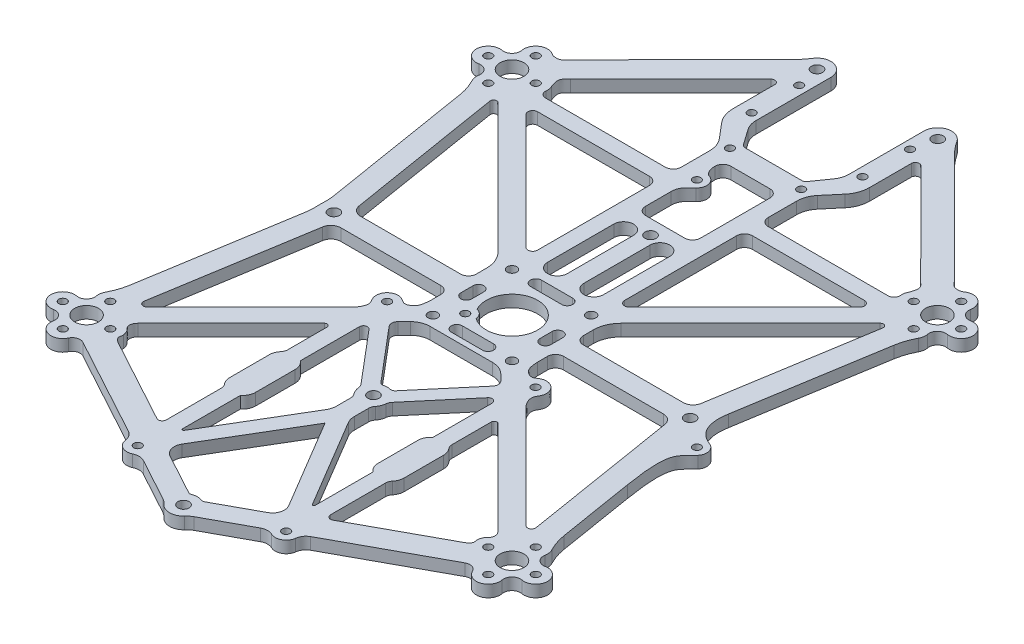
from build123d import *

# Parameters (mm, degrees)
SKETCH_1_R             = 3
SKETCH_1_R_2           = 1.4
SKETCH_1_R_3           = 1.2
SKETCH_1_R_4           = 6.5
SKETCH_1_R_5           = 1
EXTRUDE_1_DEPTH        = 3
SKETCH_3_R             = 2.5
SKETCH_3_R_2           = 1
EXTRUDE_7644_DEPTH     = 3
SKETCH_4_R             = 1
CUT_EXTRUDE_7905_DEPTH = 3


with BuildPart() as part:
    # 草图1 → 凸台-拉伸1 (new body)
    with BuildSketch(Plane(origin=(0, 0, 0), x_dir=(1, 0, 0), z_dir=(0, 1, 0))):
        with BuildLine():
            Line((-54.817916589, 41.679245914), (-48.646861458, 3.735023629))
            ThreePointArc((-48.646861458, 3.735023629), (-48.467327534, 1.997597312), (-48.49098251, 0.251079899))
            ThreePointArc((-48.49098251, 0.251079899), (-48.5, 0), (-48.49098251, -0.251079899))
            ThreePointArc((-48.49098251, -0.251079899), (-48.467327534, -1.997597312), (-48.646861458, -3.735023629))
            Line((-48.646861458, -3.735023629), (-54.817916589, -41.679245914))
            ThreePointArc((-54.817916589, -41.679245914), (-55.411166239, -44.068510137), (-56.387231876, -46.328559815))
            ThreePointArc((-56.387231876, -46.328559815), (-56.705703037, -47.287666611), (-56.687629603, -48.298103683))
            ThreePointArc((-56.687629603, -48.298103683), (-57.275533906, -50.204466094), (-59.181896317, -50.792370397))
            ThreePointArc((-59.181896317, -50.792370397), (-62.74, -53.74), (-59.181896317, -56.687629603))
            ThreePointArc((-59.181896317, -56.687629603), (-57.275533906, -57.275533906), (-56.687629603, -59.181896317))
            ThreePointArc((-56.687629603, -59.181896317), (-54.668601571, -62.592665267), (-51.02866658, -61.024005875))
            ThreePointArc((-51.02866658, -61.024005875), (-49.846342294, -59.983233235), (-48.27779537, -60.127312923))
            Line((-48.27779537, -60.127312923), (-23.022972919, -73.868492835))
            ThreePointArc((-23.022972919, -73.868492835), (-21.97669751, -74.815722708), (-21.479329577, -76.136541319))
            ThreePointArc((-21.479329577, -76.136541319), (-20.06432318, -78.215585763), (-17.550122212, -78.274427872))
            ThreePointArc((-17.550122212, -78.274427872), (-16.170972145, -77.974625009), (-14.80735752, -78.338619264))
            Line((-14.80735752, -78.338619264), (-3.95680415, -84.242418678))
            ThreePointArc((-3.95680415, -84.242418678), (-3.238991405, -84.717315042), (-2.613257566, -85.308279385))
            ThreePointArc((-2.613257566, -85.308279385), (0, -86.48), (2.613257566, -85.308279385))
            ThreePointArc((2.613257566, -85.308279385), (3.238991405, -84.717315042), (3.95680415, -84.242418678))
            Line((3.95680415, -84.242418678), (14.80735752, -78.338619264))
            ThreePointArc((14.80735752, -78.338619264), (16.170972145, -77.974625009), (17.550122212, -78.274427872))
            ThreePointArc((17.550122212, -78.274427872), (20.06432318, -78.215585763), (21.479329577, -76.136541319))
            ThreePointArc((21.479329577, -76.136541319), (21.97669751, -74.815722708), (23.022972919, -73.868492835))
            Line((23.022972919, -73.868492835), (48.27779537, -60.127312923))
            ThreePointArc((48.27779537, -60.127312923), (49.846342294, -59.983233235), (51.02866658, -61.024005875))
            ThreePointArc((51.02866658, -61.024005875), (54.668601571, -62.592665267), (56.687629603, -59.181896317))
            ThreePointArc((56.687629603, -59.181896317), (57.275533906, -57.275533906), (59.181896317, -56.687629603))
            ThreePointArc((59.181896317, -56.687629603), (62.74, -53.74), (59.181896317, -50.792370397))
            ThreePointArc((59.181896317, -50.792370397), (57.275533906, -50.204466094), (56.687629603, -48.298103683))
            ThreePointArc((56.687629603, -48.298103683), (56.705703037, -47.287666611), (56.387231876, -46.328559815))
            ThreePointArc((56.387231876, -46.328559815), (55.411166239, -44.068510137), (54.817916589, -41.679245914))
            Line((54.817916589, -41.679245914), (48.646861458, -3.735023629))
            ThreePointArc((48.646861458, -3.735023629), (48.467327534, -1.997597312), (48.49098251, -0.251079899))
            ThreePointArc((48.49098251, -0.251079899), (48.5, 0), (48.49098251, 0.251079899))
            ThreePointArc((48.49098251, 0.251079899), (48.467327534, 1.997597312), (48.646861458, 3.735023629))
            Line((48.646861458, 3.735023629), (54.817916589, 41.679245914))
            ThreePointArc((54.817916589, 41.679245914), (55.411166239, 44.068510137), (56.387231876, 46.328559815))
            ThreePointArc((56.387231876, 46.328559815), (56.705703037, 47.287666611), (56.687629603, 48.298103683))
            ThreePointArc((56.687629603, 48.298103683), (57.275533906, 50.204466094), (59.181896317, 50.792370397))
            ThreePointArc((59.181896317, 50.792370397), (62.74, 53.74), (59.181896317, 56.687629603))
            ThreePointArc((59.181896317, 56.687629603), (57.275533906, 57.275533906), (56.687629603, 59.181896317))
            ThreePointArc((56.687629603, 59.181896317), (55.338265706, 62.278808132), (51.962363808, 62.156611175))
            add(Edge.make_bspline(
                [(51.962363808, 62.156611175), (51.696992634, 61.961406663), (50.926121561, 61.800184127), (49.494642895, 61.880063213), (48.851457079, 62.883933878), (48.496350597, 63.239686175)],
                knots=[0, 0, 0, 0, 0.236574091, 0.582738494, 1, 1, 1, 1], degree=3))
            Line((48.496350597, 63.239686175), (20.779693132, 91.006750656))
            ThreePointArc((20.779693132, 91.006750656), (19.397862757, 92.54208186), (18.181759519, 94.211749492))
            ThreePointArc((18.181759519, 94.211749492), (14.252793481, 95.654933555), (11.75, 92.3))
            Line((11.75, 92.3), (11.75, 73.360558254))
            ThreePointArc((11.75, 73.360558254), (11.518584754, 71.857029257), (10.845760221, 70.492676073))
            Line((10.845760221, 70.492676073), (8.033549939, 66.476423564))
            ThreePointArc((8.033549939, 66.476423564), (7.676146508, 66.162989167), (7.214397895, 66.05))
            Line((7.214397895, 66.05), (-7.214397895, 66.05))
            ThreePointArc((-7.214397895, 66.05), (-7.676146508, 66.162989167), (-8.033549939, 66.476423564))
            Line((-8.033549939, 66.476423564), (-10.845760221, 70.492676073))
            ThreePointArc((-10.845760221, 70.492676073), (-11.518584754, 71.857029257), (-11.75, 73.360558254))
            Line((-11.75, 73.360558254), (-11.75, 92.3))
            ThreePointArc((-11.75, 92.3), (-14.252793481, 95.654933555), (-18.181759519, 94.211749492))
            ThreePointArc((-18.181759519, 94.211749492), (-19.397862757, 92.54208186), (-20.779693132, 91.006750656))
            Line((-20.779693132, 91.006750656), (-48.496350597, 63.239686175))
            add(Edge.make_bspline(
                [(-51.962363808, 62.156611175), (-51.696992634, 61.961406663), (-50.926121561, 61.800184127), (-49.494642895, 61.880063213), (-48.851457079, 62.883933878), (-48.496350597, 63.239686175)],
                knots=[0, 0, 0, 0, 0.236574091, 0.582738494, 1, 1, 1, 1], degree=3))
            ThreePointArc((-51.962363808, 62.156611175), (-55.338265706, 62.278808132), (-56.687629603, 59.181896317))
            ThreePointArc((-56.687629603, 59.181896317), (-57.275533906, 57.275533906), (-59.181896317, 56.687629603))
            ThreePointArc((-59.181896317, 56.687629603), (-62.74, 53.74), (-59.181896317, 50.792370397))
            ThreePointArc((-59.181896317, 50.792370397), (-57.275533906, 50.204466094), (-56.687629603, 48.298103683))
            ThreePointArc((-56.687629603, 48.298103683), (-56.705703037, 47.287666611), (-56.387231876, 46.328559815))
            ThreePointArc((-56.387231876, 46.328559815), (-55.411166239, 44.068510137), (-54.817916589, 41.679245914))
        make_face()
        with Locations((53.74, 53.74)):
            Circle(SKETCH_1_R, mode=Mode.SUBTRACT)
        with Locations((53.74, -53.74)):
            Circle(SKETCH_1_R, mode=Mode.SUBTRACT)
        with Locations((-53.74, -53.74)):
            Circle(SKETCH_1_R, mode=Mode.SUBTRACT)
        with Locations((-53.74, 53.74)):
            Circle(SKETCH_1_R, mode=Mode.SUBTRACT)
        with Locations((15.25, 92.3)):
            Circle(SKETCH_1_R_2, mode=Mode.SUBTRACT)
        with Locations((45, 0)):
            Circle(SKETCH_1_R_2, mode=Mode.SUBTRACT)
        with Locations((0, -82.98)):
            Circle(SKETCH_1_R_2, mode=Mode.SUBTRACT)
        with Locations((-45, 0)):
            Circle(SKETCH_1_R_2, mode=Mode.SUBTRACT)
        with Locations((-15.25, 92.3)):
            Circle(SKETCH_1_R_2, mode=Mode.SUBTRACT)
        with Locations((-10, 10)):
            Circle(SKETCH_1_R_3, mode=Mode.SUBTRACT)
        with Locations((-10, -10)):
            Circle(SKETCH_1_R_3, mode=Mode.SUBTRACT)
        with Locations((10, -10)):
            Circle(SKETCH_1_R_3, mode=Mode.SUBTRACT)
        with Locations((10, 10)):
            Circle(SKETCH_1_R_3, mode=Mode.SUBTRACT)
        Circle(SKETCH_1_R_4, mode=Mode.SUBTRACT)
        with Locations((53.74, 59.74)):
            Circle(SKETCH_1_R_5, mode=Mode.SUBTRACT)
        with Locations((59.74, 53.74)):
            Circle(SKETCH_1_R_5, mode=Mode.SUBTRACT)
        with Locations((53.74, 47.74)):
            Circle(SKETCH_1_R_5, mode=Mode.SUBTRACT)
        with Locations((47.74, 53.74)):
            Circle(SKETCH_1_R_5, mode=Mode.SUBTRACT)
        with Locations((-59.74, 53.74)):
            Circle(SKETCH_1_R_5, mode=Mode.SUBTRACT)
        with Locations((-53.74, 47.74)):
            Circle(SKETCH_1_R_5, mode=Mode.SUBTRACT)
        with Locations((-47.74, 53.74)):
            Circle(SKETCH_1_R_5, mode=Mode.SUBTRACT)
        with Locations((-53.74, 59.74)):
            Circle(SKETCH_1_R_5, mode=Mode.SUBTRACT)
        with Locations((59.74, -53.74)):
            Circle(SKETCH_1_R_5, mode=Mode.SUBTRACT)
        with Locations((47.74, -53.74)):
            Circle(SKETCH_1_R_5, mode=Mode.SUBTRACT)
        with Locations((53.74, -47.74)):
            Circle(SKETCH_1_R_5, mode=Mode.SUBTRACT)
        with Locations((53.74, -59.74)):
            Circle(SKETCH_1_R_5, mode=Mode.SUBTRACT)
        with Locations((-59.74, -53.74)):
            Circle(SKETCH_1_R_5, mode=Mode.SUBTRACT)
        with Locations((-53.74, -47.74)):
            Circle(SKETCH_1_R_5, mode=Mode.SUBTRACT)
        with Locations((-53.74, -59.74)):
            Circle(SKETCH_1_R_5, mode=Mode.SUBTRACT)
        with Locations((-47.74, -53.74)):
            Circle(SKETCH_1_R_5, mode=Mode.SUBTRACT)
        with Locations((0, 35)):
            Circle(SKETCH_1_R_2, mode=Mode.SUBTRACT)
        with Locations((0, -35)):
            Circle(SKETCH_1_R_2, mode=Mode.SUBTRACT)
        with Locations((-14, 86.55)):
            Circle(SKETCH_1_R_5, mode=Mode.SUBTRACT)
        with Locations((-14, 74.55)):
            Circle(SKETCH_1_R_5, mode=Mode.SUBTRACT)
        with Locations((-9, 64.05)):
            Circle(SKETCH_1_R_5, mode=Mode.SUBTRACT)
        with Locations((-18.75, -12.8)):
            Circle(SKETCH_1_R_5, mode=Mode.SUBTRACT)
        with Locations((18.75, -12.8)):
            Circle(SKETCH_1_R_5, mode=Mode.SUBTRACT)
        with Locations((-18.75, -75.8)):
            Circle(SKETCH_1_R_5, mode=Mode.SUBTRACT)
        with Locations((18.75, -75.8)):
            Circle(SKETCH_1_R_5, mode=Mode.SUBTRACT)
        with Locations((9, 64.05)):
            Circle(SKETCH_1_R_5, mode=Mode.SUBTRACT)
        with Locations((14, 74.55)):
            Circle(SKETCH_1_R_5, mode=Mode.SUBTRACT)
        with Locations((14, 86.55)):
            Circle(SKETCH_1_R_5, mode=Mode.SUBTRACT)
        with BuildLine():
            Line((-44.249857219, 59.000901681), (-18.957748896, 84.339007603))
            ThreePointArc((-18.957748896, 84.339007603), (-17.86773628, 84.556596792), (-17.25, 83.63254352))
            Line((-17.25, 83.63254352), (-17.25, 73.07312754))
            ThreePointArc((-17.25, 73.07312754), (-16.822346942, 70.663925251), (-15.591641236, 68.549095169))
            Line((-15.591641236, 68.549095169), (-12.421450369, 64.805969374))
            ThreePointArc((-12.421450369, 64.805969374), (-11.366559764, 62.993257875), (-11, 60.928227341))
            Line((-11, 60.928227341), (-11, 53.74))
            ThreePointArc((-11, 53.74), (-11.585786438, 52.325786438), (-13, 51.74))
            Line((-13, 51.74), (-43.267864045, 51.74))
            ThreePointArc((-43.267864045, 51.74), (-44.385898034, 52.24), (-44.75857603, 53.406666667))
            ThreePointArc((-44.75857603, 53.406666667), (-44.784640519, 54.255606765), (-45.047586477, 55.063219339))
            add(Edge.make_bspline(
                [(-44.249857219, 59.000901681), (-44.657956515, 58.592060194), (-45.738298836, 57.797656509), (-45.460089937, 56.24706939), (-45.211821974, 55.397396645), (-45.047586477, 55.063219339)],
                knots=[0, 0, 0, 0, 0.434879643, 0.72183386, 1, 1, 1, 1], degree=3))
        make_face(mode=Mode.SUBTRACT)
        with BuildLine():
            Line((-49.630496457, 44.045545745), (-43.215059938, 4.598685496))
            ThreePointArc((-43.215059938, 4.598685496), (-42.367158841, 3.095625265), (-40.747480827, 2.5))
            Line((-40.747480827, 2.5), (-15.5, 2.5))
            ThreePointArc((-15.5, 2.5), (-14.085786438, 3.085786438), (-13.5, 4.5))
            Line((-13.5, 4.5), (-13.5, 7.064971157))
            ThreePointArc((-13.5, 7.064971157), (-14.032843272, 9.743755184), (-15.550252532, 12.014718626))
            Line((-15.550252532, 12.014718626), (-48.275185717, 44.739651811))
            ThreePointArc((-48.275185717, 44.739651811), (-49.205539589, 44.886017595), (-49.630496457, 44.045545745))
        make_face(mode=Mode.SUBTRACT)
        with BuildLine():
            Line((-42.155937957, 45.691471863), (-13.048528137, 16.584062043))
            ThreePointArc((-13.048528137, 16.584062043), (-11.740779881, 16.323934742), (-11, 17.432590181))
            Line((-11, 17.432590181), (-11, 45.74))
            ThreePointArc((-11, 45.74), (-11.585786438, 47.154213562), (-13, 47.74))
            Line((-13, 47.74), (-41.307409819, 47.74))
            ThreePointArc((-41.307409819, 47.74), (-42.416065258, 46.999220119), (-42.155937957, 45.691471863))
        make_face(mode=Mode.SUBTRACT)
        with BuildLine():
            Line((-40.747480827, -2.5), (-15.5, -2.5))
            ThreePointArc((-15.5, -2.5), (-14.085786438, -3.085786438), (-13.5, -4.5))
            Line((-13.5, -4.5), (-13.5, -7.064971157))
            add(Edge.make_bspline(
                [(-13.5, -7.064971157), (-13.5, -7.532275591), (-13.629768419, -8.480482385), (-13.985423095, -10.173330441), (-15.944235554, -11.538035465), (-17.345060978, -10.327437308), (-18.921839327, -9.849782143), (-20.914131435, -10.605251441), (-21.628856588, -12.450245795), (-21.337349804, -14.041338042), (-20.598792194, -14.921596282), (-20.539303092, -16.58070944), (-21.327386728, -17.791852822), (-21.820098193, -18.284564287)],
                knots=[0, 0, 0, 0, 0.081236858, 0.151161291, 0.290886124, 0.364496537, 0.432695755, 0.558641359, 0.672327414, 0.727732225, 0.821151545, 0.848565537, 1, 1, 1, 1], degree=3))
            Line((-21.820098193, -18.284564287), (-47.83684746, -44.301313554))
            ThreePointArc((-47.83684746, -44.301313554), (-48.9997898, -44.484270784), (-49.530985886, -43.433680972))
            Line((-49.530985886, -43.433680972), (-43.215059938, -4.598685496))
            ThreePointArc((-43.215059938, -4.598685496), (-42.367158841, -3.095625265), (-40.747480827, -2.5))
        make_face(mode=Mode.SUBTRACT)
        with BuildLine():
            Line((-43.59403656, -55.845110493), (-22.227935702, -67.47043221))
            ThreePointArc((-22.227935702, -67.47043221), (-21.239086946, -67.45166978), (-20.75, -66.592037387))
            Line((-20.75, -66.592037387), (-20.75, -52.700367627))
            ThreePointArc((-20.75, -52.700367627), (-20.872818729, -52.010302068), (-21.226190476, -51.404989483))
            ThreePointArc((-21.226190476, -51.404989483), (-21.800419565, -50.421356534), (-22, -49.3))
            Line((-22, -49.3), (-22, -39.3))
            ThreePointArc((-22, -39.3), (-21.800419565, -38.178643466), (-21.226190476, -37.195010517))
            ThreePointArc((-21.226190476, -37.195010517), (-20.872818729, -36.589697932), (-20.75, -35.899632373))
            Line((-20.75, -35.899632373), (-20.75, -25.9754834))
            ThreePointArc((-20.75, -25.9754834), (-21.182121597, -25.328767727), (-21.944974747, -25.480508653))
            Line((-21.944974747, -25.480508653), (-45.455950582, -48.991484488))
            add(Edge.make_bspline(
                [(-45.455950582, -48.991484488), (-45.968825857, -49.504359763), (-46.231848976, -50.320991769), (-46.097739166, -51.156730053), (-45.659351377, -51.578773194)],
                knots=[0, 0, 0, 0, 0.559210432, 1, 1, 1, 1], degree=3))
            ThreePointArc((-45.659351377, -51.578773194), (-45.040245498, -52.431823549), (-44.754405413, -53.446359128))
            add(Edge.make_bspline(
                [(-44.754405413, -53.446359128), (-44.717532318, -53.821266454), (-45.054582612, -54.453906843), (-44.43789803, -55.362150007), (-43.821770894, -55.721199962), (-43.59403656, -55.845110493)],
                knots=[0, 0, 0, 0, 0.347316286, 0.678667105, 1, 1, 1, 1], degree=3))
        make_face(mode=Mode.SUBTRACT)
        with BuildLine():
            Line((-2.102452168, 32.785933541), (-2.102452168, 16.071116731))
            ThreePointArc((-2.102452168, 16.071116731), (-4.590561624, 13.583007274), (-7.078671081, 16.071116731))
            Line((-7.078671081, 16.071116731), (-7.078671081, 32.785933541))
            ThreePointArc((-7.078671081, 32.785933541), (-4.590561624, 35.274042997), (-2.102452168, 32.785933541))
        make_face(mode=Mode.SUBTRACT)
        with BuildLine():
            Line((-14.986026632, -21.131025078), (-3.950386049, -34.197223528))
            ThreePointArc((-3.950386049, -34.197223528), (-3.632393684, -34.717973125), (-3.486211772, -35.310366688))
            ThreePointArc((-3.486211772, -35.310366688), (-3.24142846, -36.320280856), (-2.710911113, -37.213811405))
            ThreePointArc((-2.710911113, -37.213811405), (-2.376099766, -37.807349706), (-2.260003178, -38.478846494))
            Line((-2.260003178, -38.478846494), (-2.260003178, -42.108681952))
            ThreePointArc((-2.260003178, -42.108681952), (-2.403276188, -43.169651756), (-2.82283164, -44.154617391))
            Line((-2.82283164, -44.154617391), (-16.192212135, -66.615176622))
            ThreePointArc((-16.192212135, -66.615176622), (-16.529572735, -66.750985989), (-16.75, -66.461731464))
            Line((-16.75, -66.461731464), (-16.75, -51.861737691))
            ThreePointArc((-16.75, -51.861737691), (-15.829169639, -50.725219281), (-15.5, -49.3))
            Line((-15.5, -49.3), (-15.5, -39.3))
            ThreePointArc((-15.5, -39.3), (-15.829169639, -37.874780719), (-16.75, -36.738262309))
            Line((-16.75, -36.738262309), (-16.75, -21.776272854))
            ThreePointArc((-16.75, -21.776272854), (-16.093530663, -20.837131393), (-14.986026632, -21.131025078))
        make_face(mode=Mode.SUBTRACT)
        with BuildLine():
            Line((7.900505063, -12.8), (-7.900505063, -12.8))
            ThreePointArc((-7.900505063, -12.8), (-9.813922225, -13.180602337), (-11.436038969, -14.264466094))
            Line((-11.436038969, -14.264466094), (-12.980899852, -15.809326977))
            ThreePointArc((-12.980899852, -15.809326977), (-13.448116309, -16.873477139), (-13.07188639, -17.97309427))
            Line((-13.07188639, -17.97309427), (-1.837103576, -31.275077122))
            ThreePointArc((-1.837103576, -31.275077122), (-1.382307289, -31.580833831), (-0.834656829, -31.600978379))
            ThreePointArc((-0.834656829, -31.600978379), (0, -31.5), (0.834656829, -31.600978379))
            ThreePointArc((0.834656829, -31.600978379), (1.382307289, -31.580833831), (1.837103576, -31.275077122))
            Line((1.837103576, -31.275077122), (13.07188639, -17.97309427))
            ThreePointArc((13.07188639, -17.97309427), (13.448116309, -16.873477139), (12.980899852, -15.809326977))
            Line((12.980899852, -15.809326977), (11.436038969, -14.264466094))
            ThreePointArc((11.436038969, -14.264466094), (9.813922225, -13.180602337), (7.900505063, -12.8))
        make_face(mode=Mode.SUBTRACT)
        with BuildLine():
            Line((0, -47.232643858), (-13.476555361, -69.873256865))
            ThreePointArc((-13.476555361, -69.873256865), (-13.791749788, -72.20151456), (-12.332483813, -74.042892913))
            Line((-12.332483813, -74.042892913), (-1.964243599, -79.684265147))
            ThreePointArc((-1.964243599, -79.684265147), (-1.630493999, -79.780071762), (-1.287588984, -79.725447095))
            ThreePointArc((-1.287588984, -79.725447095), (0, -79.48), (1.287588984, -79.725447095))
            ThreePointArc((1.287588984, -79.725447095), (1.630493999, -79.780071762), (1.964243599, -79.684265147))
            Line((1.964243599, -79.684265147), (12.332483813, -74.042892913))
            ThreePointArc((12.332483813, -74.042892913), (13.791749788, -72.20151456), (13.476555361, -69.873256865))
            Line((13.476555361, -69.873256865), (0, -47.232643858))
        make_face(mode=Mode.SUBTRACT)
        with BuildLine():
            Line((2.102452168, 32.785933541), (2.102452168, 16.071116731))
            ThreePointArc((2.102452168, 16.071116731), (4.590561624, 13.583007274), (7.078671081, 16.071116731))
            Line((7.078671081, 16.071116731), (7.078671081, 32.785933541))
            ThreePointArc((7.078671081, 32.785933541), (4.590561624, 35.274042997), (2.102452168, 32.785933541))
        make_face(mode=Mode.SUBTRACT)
        with BuildLine():
            Line((16.75, -51.861737691), (16.75, -66.461731464))
            ThreePointArc((16.75, -66.461731464), (16.529572735, -66.750985989), (16.192212135, -66.615176622))
            Line((16.192212135, -66.615176622), (2.82283164, -44.154617391))
            ThreePointArc((2.82283164, -44.154617391), (2.403276188, -43.169651756), (2.260003178, -42.108681952))
            Line((2.260003178, -42.108681952), (2.260003178, -38.478846494))
            ThreePointArc((2.260003178, -38.478846494), (2.376099766, -37.807349706), (2.710911113, -37.213811405))
            ThreePointArc((2.710911113, -37.213811405), (3.24142846, -36.320280856), (3.486211772, -35.310366688))
            ThreePointArc((3.486211772, -35.310366688), (3.632393684, -34.717973125), (3.950386049, -34.197223528))
            Line((3.950386049, -34.197223528), (14.986026632, -21.131025078))
            ThreePointArc((14.986026632, -21.131025078), (16.093530663, -20.837131393), (16.75, -21.776272854))
            Line((16.75, -21.776272854), (16.75, -36.738262309))
            ThreePointArc((16.75, -36.738262309), (15.829169639, -37.874780719), (15.5, -39.3))
            Line((15.5, -39.3), (15.5, -49.3))
            ThreePointArc((15.5, -49.3), (15.829169639, -50.725219281), (16.75, -51.861737691))
        make_face(mode=Mode.SUBTRACT)
        with BuildLine():
            Line((22, -39.3), (22, -49.3))
            ThreePointArc((22, -49.3), (21.800419565, -50.421356534), (21.226190476, -51.404989483))
            ThreePointArc((21.226190476, -51.404989483), (20.872818729, -52.010302068), (20.75, -52.700367627))
            Line((20.75, -52.700367627), (20.75, -66.592037387))
            ThreePointArc((20.75, -66.592037387), (21.239086946, -67.45166978), (22.227935702, -67.47043221))
            Line((22.227935702, -67.47043221), (43.59403656, -55.845110493))
            add(Edge.make_bspline(
                [(44.754405413, -53.446359128), (44.717532318, -53.821266454), (45.054582612, -54.453906843), (44.43789803, -55.362150007), (43.821770894, -55.721199962), (43.59403656, -55.845110493)],
                knots=[0, 0, 0, 0, 0.347316286, 0.678667105, 1, 1, 1, 1], degree=3))
            ThreePointArc((44.754405413, -53.446359128), (45.040245498, -52.431823549), (45.659351377, -51.578773194))
            add(Edge.make_bspline(
                [(45.455950582, -48.991484488), (45.968825857, -49.504359763), (46.231848976, -50.320991769), (46.097739166, -51.156730053), (45.659351377, -51.578773194)],
                knots=[0, 0, 0, 0, 0.559210432, 1, 1, 1, 1], degree=3))
            Line((45.455950582, -48.991484488), (21.944974747, -25.480508653))
            ThreePointArc((21.944974747, -25.480508653), (21.182121597, -25.328767727), (20.75, -25.9754834))
            Line((20.75, -25.9754834), (20.75, -35.899632373))
            ThreePointArc((20.75, -35.899632373), (20.872818729, -36.589697932), (21.226190476, -37.195010517))
            ThreePointArc((21.226190476, -37.195010517), (21.800419565, -38.178643466), (22, -39.3))
        make_face(mode=Mode.SUBTRACT)
        with BuildLine():
            Line((13.5, -4.5), (13.5, -7.064971157))
            add(Edge.make_bspline(
                [(13.5, -7.064971157), (13.5, -7.532275591), (13.629768419, -8.480482385), (13.985423095, -10.173330441), (15.944235554, -11.538035465), (17.345060978, -10.327437308), (18.921839327, -9.849782143), (20.914131435, -10.605251441), (21.628856588, -12.450245795), (21.337349804, -14.041338042), (20.598792194, -14.921596282), (20.539303092, -16.58070944), (21.327386728, -17.791852822), (21.820098193, -18.284564287)],
                knots=[0, 0, 0, 0, 0.081236858, 0.151161291, 0.290886124, 0.364496537, 0.432695755, 0.558641359, 0.672327414, 0.727732225, 0.821151545, 0.848565537, 1, 1, 1, 1], degree=3))
            Line((21.820098193, -18.284564287), (47.83684746, -44.301313554))
            ThreePointArc((47.83684746, -44.301313554), (48.9997898, -44.484270784), (49.530985886, -43.433680972))
            Line((49.530985886, -43.433680972), (43.215059938, -4.598685496))
            ThreePointArc((43.215059938, -4.598685496), (42.367158841, -3.095625265), (40.747480827, -2.5))
            Line((40.747480827, -2.5), (15.5, -2.5))
            ThreePointArc((15.5, -2.5), (14.085786438, -3.085786438), (13.5, -4.5))
        make_face(mode=Mode.SUBTRACT)
        with BuildLine():
            Line((48.275185717, 44.739651811), (15.550252532, 12.014718626))
            ThreePointArc((15.550252532, 12.014718626), (14.032843272, 9.743755184), (13.5, 7.064971157))
            Line((13.5, 7.064971157), (13.5, 4.5))
            ThreePointArc((13.5, 4.5), (14.085786438, 3.085786438), (15.5, 2.5))
            Line((15.5, 2.5), (40.747480827, 2.5))
            ThreePointArc((40.747480827, 2.5), (42.367158841, 3.095625265), (43.215059938, 4.598685496))
            Line((43.215059938, 4.598685496), (49.630496457, 44.045545745))
            ThreePointArc((49.630496457, 44.045545745), (49.205539589, 44.886017595), (48.275185717, 44.739651811))
        make_face(mode=Mode.SUBTRACT)
        with BuildLine():
            Line((41.307409819, 47.74), (13, 47.74))
            ThreePointArc((13, 47.74), (11.585786438, 47.154213562), (11, 45.74))
            Line((11, 45.74), (11, 17.432590181))
            ThreePointArc((11, 17.432590181), (11.740779881, 16.323934742), (13.048528137, 16.584062043))
            Line((13.048528137, 16.584062043), (42.155937957, 45.691471863))
            ThreePointArc((42.155937957, 45.691471863), (42.416065258, 46.999220119), (41.307409819, 47.74))
        make_face(mode=Mode.SUBTRACT)
        with BuildLine():
            Line((11, 60.928227341), (11, 53.74))
            ThreePointArc((11, 53.74), (11.585786438, 52.325786438), (13, 51.74))
            Line((13, 51.74), (43.267864045, 51.74))
            ThreePointArc((43.267864045, 51.74), (44.385898034, 52.24), (44.75857603, 53.406666667))
            ThreePointArc((44.75857603, 53.406666667), (44.784640519, 54.255606765), (45.047586477, 55.063219339))
            add(Edge.make_bspline(
                [(44.249857219, 59.000901681), (44.657956515, 58.592060194), (45.738298836, 57.797656509), (45.460089937, 56.24706939), (45.211821974, 55.397396645), (45.047586477, 55.063219339)],
                knots=[0, 0, 0, 0, 0.434879643, 0.72183386, 1, 1, 1, 1], degree=3))
            Line((44.249857219, 59.000901681), (18.957748896, 84.339007603))
            ThreePointArc((18.957748896, 84.339007603), (17.86773628, 84.556596792), (17.25, 83.63254352))
            Line((17.25, 83.63254352), (17.25, 73.07312754))
            ThreePointArc((17.25, 73.07312754), (16.822346942, 70.663925251), (15.591641236, 68.549095169))
            Line((15.591641236, 68.549095169), (12.421450369, 64.805969374))
            ThreePointArc((12.421450369, 64.805969374), (11.366559764, 62.993257875), (11, 60.928227341))
        make_face(mode=Mode.SUBTRACT)
        with BuildLine():
            Line((-4.954241029, 60.224971884), (4.954241029, 60.224971884))
            ThreePointArc((4.954241029, 60.224971884), (6.368454591, 59.639185446), (6.954241029, 58.224971884))
            Line((6.954241029, 58.224971884), (6.954241029, 40.664246406))
            ThreePointArc((6.954241029, 40.664246406), (6.368454591, 39.250032844), (4.954241029, 38.664246406))
            Line((4.954241029, 38.664246406), (-4.954241029, 38.664246406))
            ThreePointArc((-4.954241029, 38.664246406), (-6.368454591, 39.250032844), (-6.954241029, 40.664246406))
            Line((-6.954241029, 40.664246406), (-6.954241029, 58.224971884))
            ThreePointArc((-6.954241029, 58.224971884), (-6.368454591, 59.639185446), (-4.954241029, 60.224971884))
        make_face(mode=Mode.SUBTRACT)
        with BuildLine():
            Line((-8.64449975, 1.539057698), (-8.64449975, -1.539057698))
            ThreePointArc((-8.64449975, -1.539057698), (-10, -2.894557949), (-11.35550025, -1.539057698))
            Line((-11.35550025, -1.539057698), (-11.35550025, 1.539057698))
            ThreePointArc((-11.35550025, 1.539057698), (-10, 2.894557949), (-8.64449975, 1.539057698))
        make_face(mode=Mode.SUBTRACT)
        with BuildLine():
            Line((-3.950386049, -8.60938361), (3.950386049, -8.60938361))
            ThreePointArc((3.950386049, -8.60938361), (5.341002439, -10), (3.950386049, -11.39061639))
            Line((3.950386049, -11.39061639), (-3.950386049, -11.39061639))
            ThreePointArc((-3.950386049, -11.39061639), (-5.341002439, -10), (-3.950386049, -8.60938361))
        make_face(mode=Mode.SUBTRACT)
        with BuildLine():
            Line((-3.950386049, 8.60938361), (3.950386049, 8.60938361))
            ThreePointArc((3.950386049, 8.60938361), (5.341002439, 10), (3.950386049, 11.39061639))
            Line((3.950386049, 11.39061639), (-3.950386049, 11.39061639))
            ThreePointArc((-3.950386049, 11.39061639), (-5.341002439, 10), (-3.950386049, 8.60938361))
        make_face(mode=Mode.SUBTRACT)
        with BuildLine():
            Line((8.64449975, 1.539057698), (8.64449975, -1.539057698))
            ThreePointArc((8.64449975, -1.539057698), (10, -2.894557949), (11.35550025, -1.539057698))
            Line((11.35550025, -1.539057698), (11.35550025, 1.539057698))
            ThreePointArc((11.35550025, 1.539057698), (10, 2.894557949), (8.64449975, 1.539057698))
        make_face(mode=Mode.SUBTRACT)
    extrude(amount=EXTRUDE_1_DEPTH)

    # 草图3 → Extrude 7644 (add)
    with BuildSketch(Plane(origin=(0, 3, 0), x_dir=(1, 0, 0), z_dir=(0, 1, 0))):
        with Locations((-6.25, -5.55)):
            Circle(SKETCH_3_R)
        with Locations((-6.25, -5.55)):
            Circle(SKETCH_3_R_2, mode=Mode.SUBTRACT)
        with BuildLine():
            Line((51.704116611, -22.533295015), (49.272931319, -22.533295015))
            Line((49.272931319, -22.533295015), (47.916422955, -14.507656058))
            Line((47.916422955, -14.507656058), (46.960900681, -2.586574972))
            Line((46.960900681, -2.586574972), (47.675751234, 6.403470128))
            Line((47.675751234, 6.403470128), (48.969242404, 5.717260707))
            add(Edge.make_bspline(
                [(53.111900251, -3.203272926), (47.841682978, -1.215810639), (48.969242404, 5.717260707)],
                knots=[0, 0, 0, 1, 1, 1], degree=2))
            ThreePointArc((53.111900251, -3.203272926), (54.664016462, -4.899981138), (54.173726626, -7.146645191))
            add(Edge.make_bspline(
                [(51.704116611, -22.533295015), (49.570857958, -9.416439179), (51.762281514, -10.052087926), (54.173726626, -7.146645191)],
                knots=[0, 0, 0, 0, 1, 1, 1, 1], degree=3))
        make_face()
        with Locations((52.25, -5.55)):
            Circle(SKETCH_3_R_2, mode=Mode.SUBTRACT)
        with BuildLine():
            Line((-6.954241029, 47.162024082), (-8.930564978, 47.162024082))
            Line((-8.930564978, 47.162024082), (-9.585050817, 54.203344464))
            Line((-9.585050817, 54.203344464), (-7.942403003, 59.422774069))
            Line((-7.942403003, 59.422774069), (-6.954241029, 58.224971884))
            add(Edge.make_bspline(
                [(-5.48182533, 55.329056047), (-6.000877828, 55.496653184), (-6.703014237, 56.470984072), (-6.954241029, 57.493735816), (-6.954241029, 58.224971884)],
                knots=[0, 0, 0, 0, 0.42820393, 1, 1, 1, 1], degree=3))
            ThreePointArc((-5.48182533, 55.329056047), (-3.805827838, 53.475378378), (-4.572081778, 51.096735194))
            add(Edge.make_bspline(
                [(-4.572081778, 51.096735194), (-5.850896491, 49.93891549), (-6.954241029, 49.090146385), (-6.954241029, 47.162024082)],
                knots=[0, 0, 0, 0, 1, 1, 1, 1], degree=3))
        make_face()
        with Locations((-6.25, 52.95)):
            Circle(SKETCH_3_R_2, mode=Mode.SUBTRACT)
    extrude(amount=-EXTRUDE_7644_DEPTH)

    # 草图4 → Cut-Extrude 7905 (cut)
    with BuildSketch(Plane(origin=(0, 3, 0), x_dir=(1, 0, 0), z_dir=(0, 1, 0))):
        with Locations((-6.25, -5.55)):
            Circle(SKETCH_4_R)
        with Locations((-6.25, 52.95)):
            Circle(SKETCH_4_R)
    extrude(amount=-CUT_EXTRUDE_7905_DEPTH, mode=Mode.SUBTRACT)


solid = part.part
